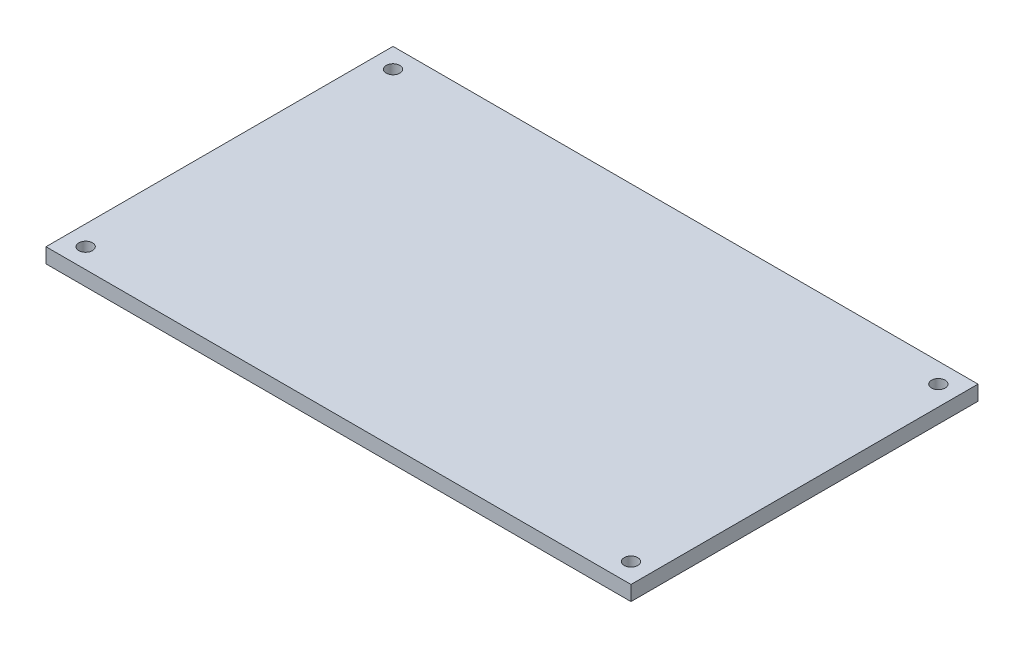
from build123d import *

# Parameters (mm, degrees)
SKETCH1_W           = 118
SKETCH1_H           = 70
SKETCH1_R           = 1.375
BOSS_EXTRUDE1_DEPTH = 3


with BuildPart() as part:
    # Sketch1 → Boss-Extrude1 (new body)
    with BuildSketch(Plane(origin=(0, 0, 0), x_dir=(1, 0, 0), z_dir=(0, 1, 0))):
        Rectangle(SKETCH1_W, SKETCH1_H)
        with Locations((-55, 31)):
            Circle(SKETCH1_R, mode=Mode.SUBTRACT)
        with Locations((55, 31)):
            Circle(SKETCH1_R, mode=Mode.SUBTRACT)
        with Locations((55, -31)):
            Circle(SKETCH1_R, mode=Mode.SUBTRACT)
        with Locations((-55, -31)):
            Circle(SKETCH1_R, mode=Mode.SUBTRACT)
    extrude(amount=BOSS_EXTRUDE1_DEPTH)


solid = part.part
